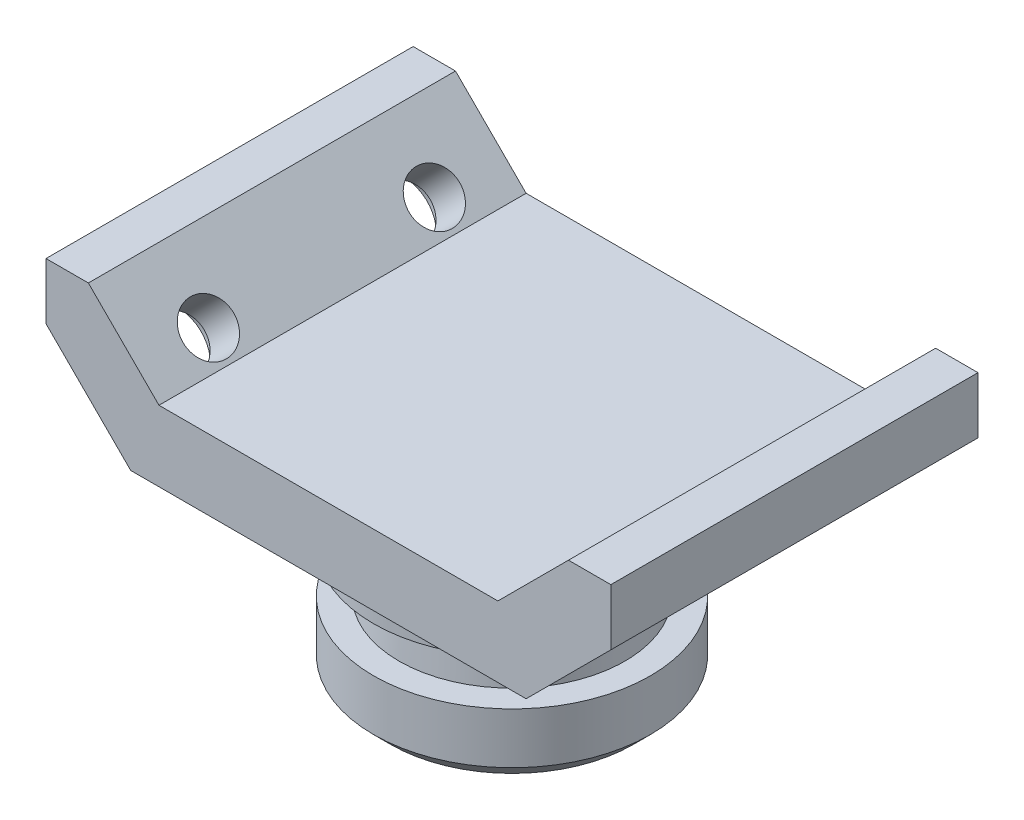
from build123d import *

# Parameters (mm, degrees)
SALIENTE_EXTRUIR1_DEPTH                     = 32.5
REFRENTADO_PARA_TORNILLO_CON_CABEZA_2_COUNT = 2
REFRENTADO_PARA_TORNILLO_CON_CABEZA_2_PITCH = 40


with BuildPart() as part:
    # Croquis2 → Saliente-Extruir1 (new body, symmetric)
    with BuildSketch(Plane.XY):
        Polygon((-30, 0), (30, 0), (42.5, 12.5), (50, 12.5), (50, 2.5), (35, -12.5), (-35, -12.5), (-50, 2.5), (-50, 12.5), (-42.5, 12.5), align=None)
    extrude(amount=SALIENTE_EXTRUIR1_DEPTH, both=True)

    # Croquis3 → Revolución1 (revolve)
    with BuildSketch(Plane.XY):
        Polygon((0, -12.5), (-24.5, -12.5), (-24.5, -22.5), (-19.5, -22.5), (-20, -30.484359711), (-24.5, -30.484359711), (-24.5, -39.5), (-21.5, -42.5), (0, -42.5), align=None)
    revolve(axis=Axis((0, -42.5, 0), (0, 1, 0)))

    # Croquis5 → Refrentado para tornillo con cabeza plana de M81 (revolve, cut)
    with BuildSketch(Plane(origin=(-42.5, -5, -20), x_dir=(0.707106781, -0.707106781, 0), z_dir=(0, 0, 1))):
        Polygon((0, 0), (0, 77.781745931), (4.5, 77.781745931), (4.5, 5), (7.5, 5), (7.5, 0), align=None)
    refrentado_para_tornillo_con_cabeza_plan = revolve(axis=Axis((-46.990128061, -9.490128061, -20), (0.707106781, 0.707106781, 0)), mode=Mode.SUBTRACT)

    # Refrentado para tornillo con cabeza  2: Refrentado para tornillo con cabeza plana de M81 ×2
    with Locations(*[(0, 0, i * REFRENTADO_PARA_TORNILLO_CON_CABEZA_2_PITCH) for i in range(1, REFRENTADO_PARA_TORNILLO_CON_CABEZA_2_COUNT)]):
        add(refrentado_para_tornillo_con_cabeza_plan, mode=Mode.SUBTRACT)

    # Simetría1: Refrentado para tornillo con cabeza plana de M81 across plane
    add(refrentado_para_tornillo_con_cabeza_plan.mirror(Plane(origin=(0, 0, 0), x_dir=(0, 0, 1), z_dir=(1, 0, 0))), mode=Mode.SUBTRACT)

    # Simetría1 copy 1 sketch → Simetría1 copy 1 (revolve, cut)
    with BuildSketch(Plane(origin=(42.5, -5, 20), x_dir=(-0.707106781, -0.707106781, 0), z_dir=(0, 0, 1))):
        Polygon((0, 0), (0, -77.781745931), (4.5, -77.781745931), (4.5, -5), (7.5, -5), (7.5, 0), align=None)
    revolve(axis=Axis((46.990128061, -9.490128061, 20), (0.707106781, -0.707106781, 0)), mode=Mode.SUBTRACT)


solid = part.part
